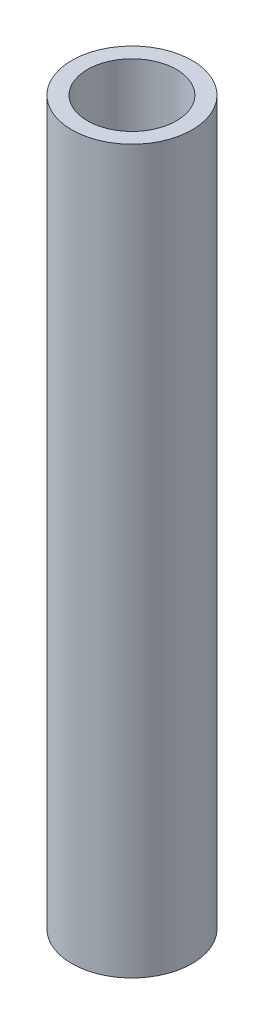
from build123d import *

# Parameters (mm, degrees)
SKETCH1_R           = 6.35
SKETCH1_R_2         = 4.699
BOSS_EXTRUDE1_DEPTH = 76.2


with BuildPart() as part:
    # Sketch1 → Boss-Extrude1 (new body)
    with BuildSketch(Plane(origin=(0, 0, 0), x_dir=(1, 0, 0), z_dir=(0, 1, 0))):
        Circle(SKETCH1_R)
        Circle(SKETCH1_R_2, mode=Mode.SUBTRACT)
    extrude(amount=BOSS_EXTRUDE1_DEPTH)


solid = part.part
